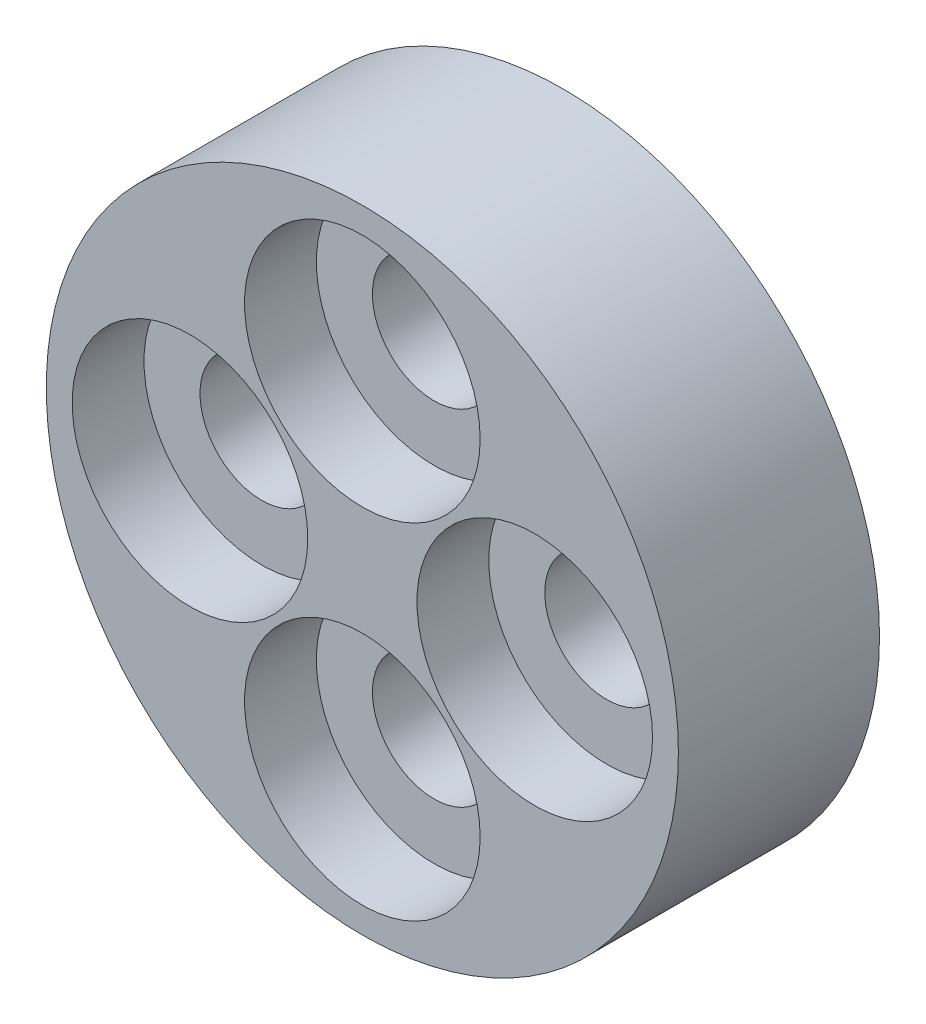
from build123d import *

# Parameters (mm, degrees)
SKETCH1_R           = 11
BOSS_EXTRUDE1_DEPTH = 7
SKETCH2_R           = 4.1
CUT_EXTRUDE1_DEPTH  = 2.5
SKETCH3_R           = 2.15
CUT_EXTRUDE2_DEPTH  = 10


with BuildPart() as part:
    # Sketch1 → Boss-Extrude1 (new body)
    with BuildSketch(Plane.XY):
        Circle(SKETCH1_R)
    extrude(amount=BOSS_EXTRUDE1_DEPTH)

    # Sketch2 → Cut-Extrude1 (cut)
    with BuildSketch(Plane.XY.offset(7)):
        with Locations((0, 6)):
            Circle(SKETCH2_R)
        with Locations((6, 0)):
            Circle(SKETCH2_R)
        with Locations((0, -6)):
            Circle(SKETCH2_R)
        with Locations((-6, 0)):
            Circle(SKETCH2_R)
    extrude(amount=-CUT_EXTRUDE1_DEPTH, mode=Mode.SUBTRACT)

    # Sketch3 → Cut-Extrude2 (cut)
    with BuildSketch(Plane.XY.offset(4.5)):
        with Locations((0, -6)):
            Circle(SKETCH3_R)
        with Locations((-6, 0)):
            Circle(SKETCH3_R)
        with Locations((0, 6)):
            Circle(SKETCH3_R)
        with Locations((6, 0)):
            Circle(SKETCH3_R)
    extrude(amount=-CUT_EXTRUDE2_DEPTH, mode=Mode.SUBTRACT)


solid = part.part
